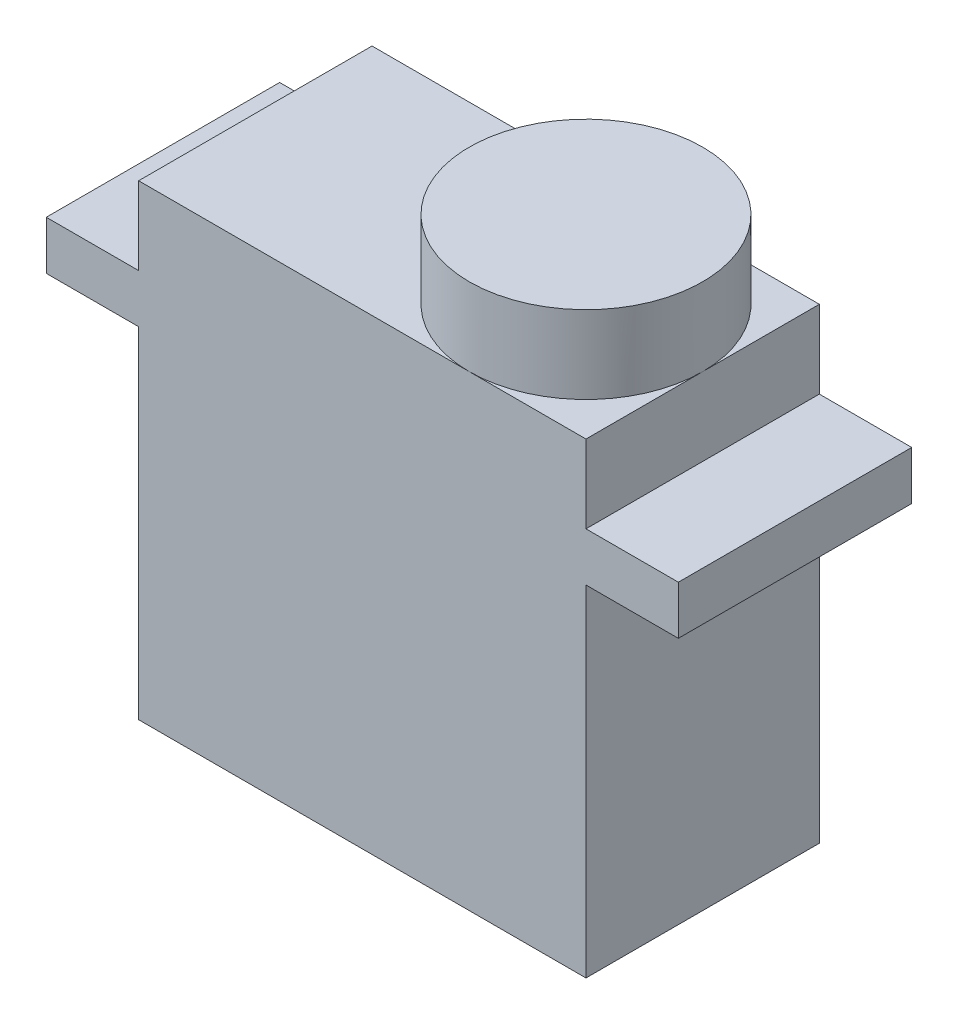
from build123d import *

# Parameters (mm, degrees)
SKETCH1_R           = 6
BOSS_EXTRUDE1_DEPTH = 24
BOSS_EXTRUDE2_START = 24
SKETCH1_3_R         = 6
BOSS_EXTRUDE2_DEPTH = 4
BOSS_EXTRUDE3_START = 20
SKETCH1_4_W         = 32.5
SKETCH1_4_H         = 12
BOSS_EXTRUDE3_DEPTH = 2.5


with BuildPart() as part:
    # Sketch1 → Boss-Extrude1 (new body)
    with BuildSketch(Plane(origin=(0, 0, 0), x_dir=(1, 0, 0), z_dir=(0, 1, 0))):
        with BuildLine():
            Line((-11.5, 6), (-11.5, -6))
            Line((-11.5, -6), (5.5, -6))
            ThreePointArc((5.5, -6), (-0.5, -3e-09), (5.499999994, 6))
            Line((5.499999994, 6), (-11.5, 6))
        make_face()
        with Locations((5.5, 0)):
            Circle(SKETCH1_R)
        with BuildLine():
            Line((11.5, 6), (5.499999994, 6))
            ThreePointArc((5.499999994, 6), (9.742640685, 4.242640689), (11.5, 0))
            Line((11.5, 0), (11.5, 6))
        make_face()
        with BuildLine():
            ThreePointArc((11.5, 0), (9.742640687, -4.242640687), (5.5, -6))
            Line((5.5, -6), (11.5, -6))
            Line((11.5, -6), (11.5, 0))
        make_face()
    extrude(amount=BOSS_EXTRUDE1_DEPTH)

    # Sketch1_3 → Boss-Extrude2 (add)
    with BuildSketch(Plane(origin=(0, 0, 0), x_dir=(1, 0, 0), z_dir=(0, 1, 0)).offset(BOSS_EXTRUDE2_START)):
        with Locations((5.5, 0)):
            Circle(SKETCH1_3_R)
    extrude(amount=BOSS_EXTRUDE2_DEPTH)

    # Sketch1_4 → Boss-Extrude3 (add)
    with BuildSketch(Plane(origin=(0, 0, 0), x_dir=(1, 0, 0), z_dir=(0, 1, 0)).offset(BOSS_EXTRUDE3_START)):
        Rectangle(SKETCH1_4_W, SKETCH1_4_H)
    extrude(amount=-BOSS_EXTRUDE3_DEPTH)


solid = part.part
